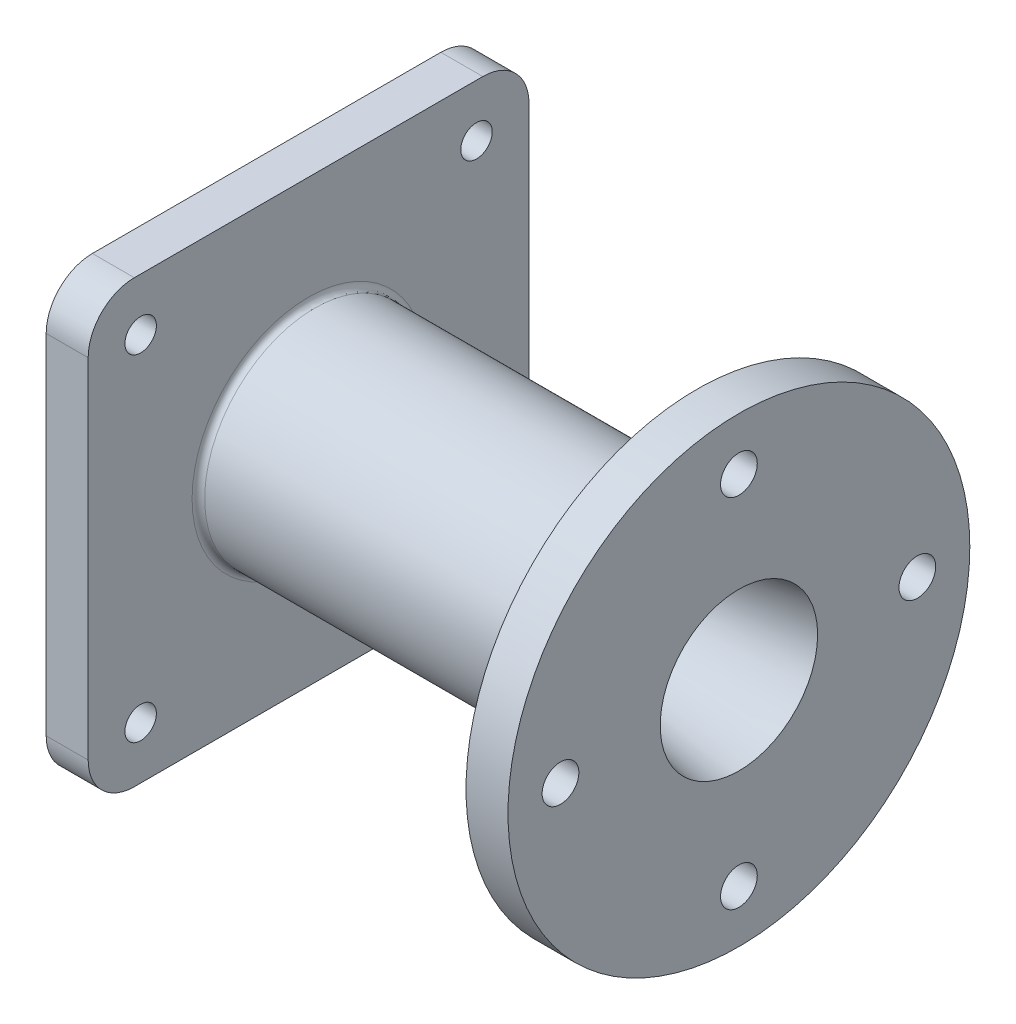
from build123d import *

# Parameters (mm, degrees)
CUT_EXTRUDE_1_REACH      = 275.542
SKETCH_2_R               = 8.75
PATTERN_CIRCULAR_1_COUNT = 4
SKETCH_3_W               = 210
SKETCH_3_H               = 210
SKETCH_3_R               = 28.7125
EXTRUDE_1_DEPTH          = 20
SKETCH_4_R               = 7.5
CUT_EXTRUDE_2_DEPTH      = 20
FILLET_1_R               = 22
PATTERN_CIRCULAR_5_COUNT = 4
FILLET_2_R               = 3
SKETCH_5_R               = 28.7125
SKETCH_5_R_2             = 27.5
EXTRUDE_2_DEPTH          = 17.5
FILLET_3_R               = 3


with BuildPart() as part:
    # Эскиз1 → Повернуть1 (revolve)
    with BuildSketch(Plane.XY, mode=Mode.PRIVATE) as revolve_1_sk:
        Polygon((0, 37.5), (0, 110), (-20, 110), (-20, 60), (-55, 52.5), (-205, 52.5), (-205, 105), (-225, 105), (-225, 62.5), (-210, 62.5), (-210, 28.7125), (-160, 28.7125), (-160, 40), (-95, 40), (-95, 28.7125), (-77.5, 28.7125), (-77.5, 25), align=None)
    revolve(revolve_1_sk.sketch.rotate(Axis((0, 0, 0), (-1, 0, 0)), 90), axis=Axis((0, 0, 0), (-1, 0, 0)))

    # Эскиз2 → Вырез-Вытянуть1 (cut, up to next)
    with BuildSketch(Plane(origin=(0, 0, 0), x_dir=(0, 0, -1), z_dir=(1, 0, 0)), mode=Mode.PRIVATE) as cut_extrude_1_sk1:
        with Locations((0, 85)):
            Circle(SKETCH_2_R)
    cut_extrude_1_tool1 = extrude(cut_extrude_1_sk1.sketch, amount=-CUT_EXTRUDE_1_REACH, mode=Mode.PRIVATE) & part.part
    cut_extrude_1 = cut_extrude_1_tool1.solids().sort_by_distance((0, 85, 0))[0]
    add(cut_extrude_1, mode=Mode.SUBTRACT)

    # Круговой массив1: Вырез-Вытянуть1 ×4 about axis
    pattern_circular_1_axis = Axis((0, 0, 0), (1, 0, 0))
    for i in range(1, PATTERN_CIRCULAR_1_COUNT):
        add(cut_extrude_1.rotate(pattern_circular_1_axis, i * 360 / PATTERN_CIRCULAR_1_COUNT), mode=Mode.SUBTRACT)

    # Эскиз3 → Бобышка-Вытянуть1 (add)
    with BuildSketch(Plane.ZY.offset(225)):
        Rectangle(SKETCH_3_W, SKETCH_3_H)
        with Locations(Location((0, 0, 0), (0, 0, 180))):
            Circle(SKETCH_3_R, mode=Mode.SUBTRACT)
    extrude(amount=-EXTRUDE_1_DEPTH)

    # Эскиз4 → Вырез-Вытянуть2 (cut)
    with BuildSketch(Plane.ZY.offset(225)):
        with Locations((80, 80)):
            Circle(SKETCH_4_R)
    cut_extrude_2 = extrude(amount=-CUT_EXTRUDE_2_DEPTH, mode=Mode.SUBTRACT)

    # Скругление1
    fillet_1_edges = [part.edges().sort_by_distance(p)[0] for p in [
        (-215, 105, 105),
        (-215, -105, 105),
        (-215, -105, -105),
        (-215, 105, -105),
    ]]
    fillet(fillet_1_edges, radius=FILLET_1_R)

    # Круговой массив5: Вырез-Вытянуть2 ×4 about axis
    pattern_circular_5_axis = Axis((0, 0, 0), (1, 0, 0))
    for i in range(1, PATTERN_CIRCULAR_5_COUNT):
        add(cut_extrude_2.rotate(pattern_circular_5_axis, i * 360 / PATTERN_CIRCULAR_5_COUNT), mode=Mode.SUBTRACT)

    # Скругление2
    fillet_2_edges = [part.edges().sort_by_distance(p)[0] for p in [
        (-160, 0, 40),
        (-95, 0, 40),
    ]]
    fillet(fillet_2_edges, radius=FILLET_2_R)

    # Эскиз5 → Бобышка-Вытянуть2 (add)
    with BuildSketch(Plane.ZY.offset(77.5)):
        with Locations(Location((0, 0, 0), (0, 0, 180))):
            Circle(SKETCH_5_R)
        with Locations(Location((0, 0, 0), (0, 0, 180))):
            Circle(SKETCH_5_R_2, mode=Mode.SUBTRACT)
    extrude(amount=EXTRUDE_2_DEPTH)

    # Скругление3
    fillet_3_edges = [part.edges().sort_by_distance(p)[0] for p in [
        (-20, 0, 60),
        (-205, 0, 52.5),
    ]]
    fillet(fillet_3_edges, radius=FILLET_3_R)


solid = part.part
